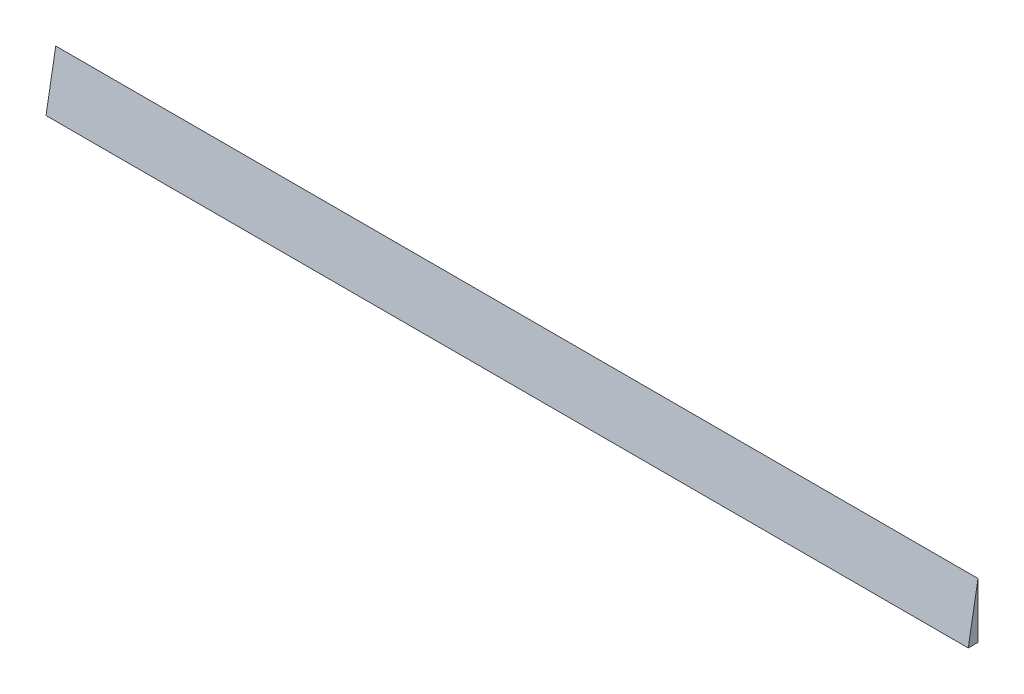
from build123d import *

# Parameters (mm, degrees)
BOSS_EXTRUDE1_DEPTH = 400


with BuildPart() as part:
    # Sketch1 → Boss-Extrude1 (new body)
    with BuildSketch(Plane(origin=(0, 0, 0), x_dir=(0, 0, -1), z_dir=(1, 0, 0))):
        Polygon((0, 0), (0, 24), (-4.231847537, 0), align=None)
    extrude(amount=BOSS_EXTRUDE1_DEPTH)


solid = part.part
